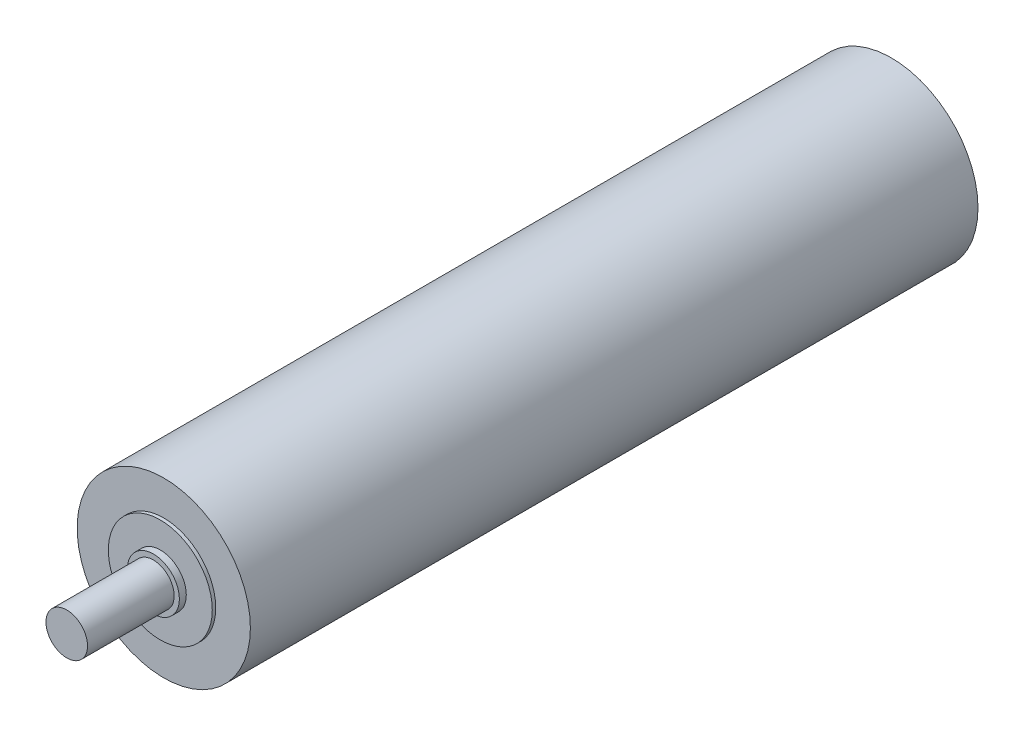
from build123d import *

# Parameters (mm, degrees)
SKETCH1_R           = 25
BOSS_EXTRUDE2_DEPTH = 210
SKETCH2_R           = 15
BOSS_EXTRUDE3_DEPTH = 1
SKETCH3_R           = 7.5
BOSS_EXTRUDE4_DEPTH = 2
SKETCH4_R           = 6
BOSS_EXTRUDE5_DEPTH = 25


with BuildPart() as part:
    # Sketch1 → Boss-Extrude2 (new body)
    with BuildSketch(Plane.XY):
        Circle(SKETCH1_R)
    extrude(amount=-BOSS_EXTRUDE2_DEPTH)

    # Sketch2 → Boss-Extrude3 (add)
    with BuildSketch(Plane.XY):
        Circle(SKETCH2_R)
    extrude(amount=BOSS_EXTRUDE3_DEPTH)

    # Sketch3 → Boss-Extrude4 (add)
    with BuildSketch(Plane.XY.offset(1)):
        Circle(SKETCH3_R)
    extrude(amount=BOSS_EXTRUDE4_DEPTH)

    # Sketch4 → Boss-Extrude5 (add)
    with BuildSketch(Plane.XY.offset(3)):
        Circle(SKETCH4_R)
    extrude(amount=BOSS_EXTRUDE5_DEPTH)


solid = part.part
